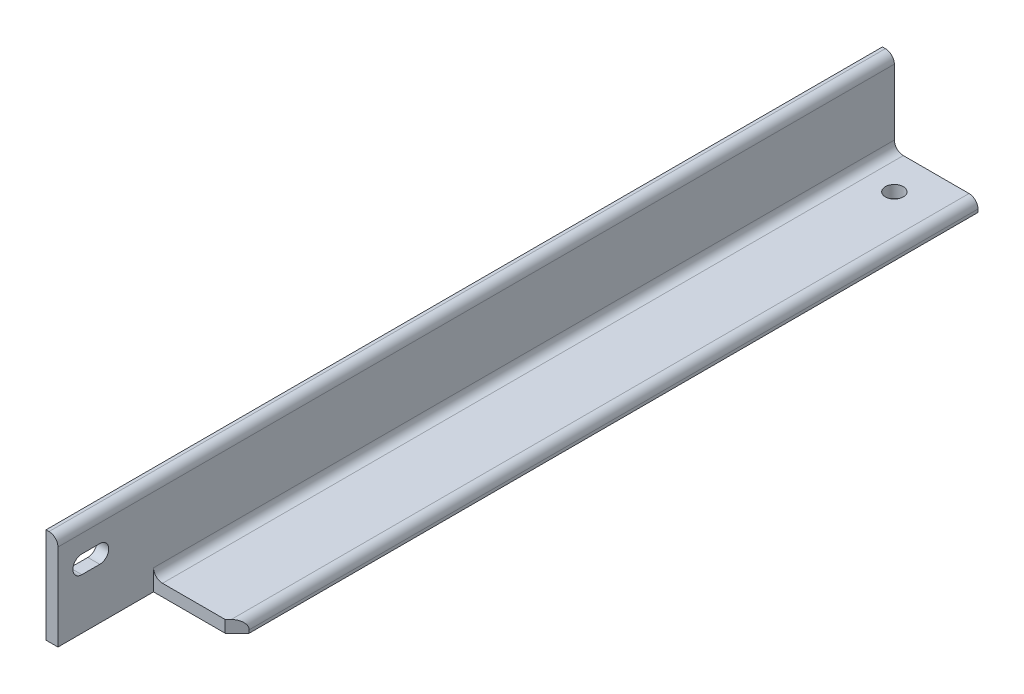
from build123d import *

# Parameters (mm, degrees)
BOSS_EXTRUDE1_DEPTH             = 444.5
CUT_EXTRUDE1_REACH              = 103.6
CUT_EXTRUDE2_REACH              = 103.6
F_3_4_0_75_DIAMETER_HOLE1_D     = 19.05
F_3_4_0_75_DIAMETER_HOLE1_DEPTH = 50.8
F_3_4_0_75_DIAMETER_HOLE1_TIP   = 5.723197396


with BuildPart() as part:
    # Sketch1 → Boss-Extrude1 (new body, symmetric)
    with BuildSketch(Plane.XY):
        with BuildLine():
            Line((0, 0), (0, 101.6))
            Line((0, 101.6), (3.18008, 101.6))
            ThreePointArc((3.18008, 101.6), (9.911679988, 98.811679988), (12.7, 92.08008))
            Line((12.7, 92.08008), (12.7, 22.225))
            ThreePointArc((12.7, 22.225), (15.489807909, 15.489807909), (22.225, 12.7))
            Line((22.225, 12.7), (92.08008, 12.7))
            ThreePointArc((92.08008, 12.7), (98.811679988, 9.911679988), (101.6, 3.18008))
            Line((101.6, 3.18008), (101.6, 0))
            Line((101.6, 0), (0, 0))
        make_face()
    extrude(amount=BOSS_EXTRUDE1_DEPTH, both=True)

    # Sketch2 → Cut-Extrude1 (cut, up to next)
    with BuildSketch(Plane.XZ, mode=Mode.PRIVATE) as cut_extrude1_sk1:
        Polygon((88.9, 342.9), (12.7, 342.9), (12.7, 444.5), (101.6, 444.5), (101.6, 342.9), (101.6, 330.2), align=None)
    cut_extrude1_tool1 = extrude(cut_extrude1_sk1.sketch, amount=-CUT_EXTRUDE1_REACH, mode=Mode.PRIVATE) & part.part
    add(cut_extrude1_tool1.solids().sort_by_distance((57.5059, 0, 393.212979))[0], mode=Mode.SUBTRACT)

    # Sketch3 → Cut-Extrude2 (cut, up to next)
    with BuildSketch(Plane.ZY, mode=Mode.PRIVATE) as cut_extrude2_sk1:
        with BuildLine():
            Line((419.1, 53.975), (400.05, 53.975))
            ThreePointArc((400.05, 53.975), (390.525, 63.5), (400.05, 73.025))
            Line((400.05, 73.025), (419.1, 73.025))
            ThreePointArc((419.1, 73.025), (428.625, 63.5), (419.1, 53.975))
        make_face()
    cut_extrude2_tool1 = extrude(cut_extrude2_sk1.sketch, amount=-CUT_EXTRUDE2_REACH, mode=Mode.PRIVATE) & part.part
    add(cut_extrude2_tool1.solids().sort_by_distance((0, 63.5, 409.575))[0], mode=Mode.SUBTRACT)

    # 3/4 (0.75) Diameter Hole1
    with Locations(Plane.XZ):
        with Locations((50.8, -406.4)):
            Hole(F_3_4_0_75_DIAMETER_HOLE1_D / 2, depth=F_3_4_0_75_DIAMETER_HOLE1_DEPTH)
            with Locations((0, 0, -(F_3_4_0_75_DIAMETER_HOLE1_DEPTH + F_3_4_0_75_DIAMETER_HOLE1_TIP / 2))):  # 118° drill point
                Cone(0, F_3_4_0_75_DIAMETER_HOLE1_D / 2, F_3_4_0_75_DIAMETER_HOLE1_TIP, mode=Mode.SUBTRACT)


solid = part.part
